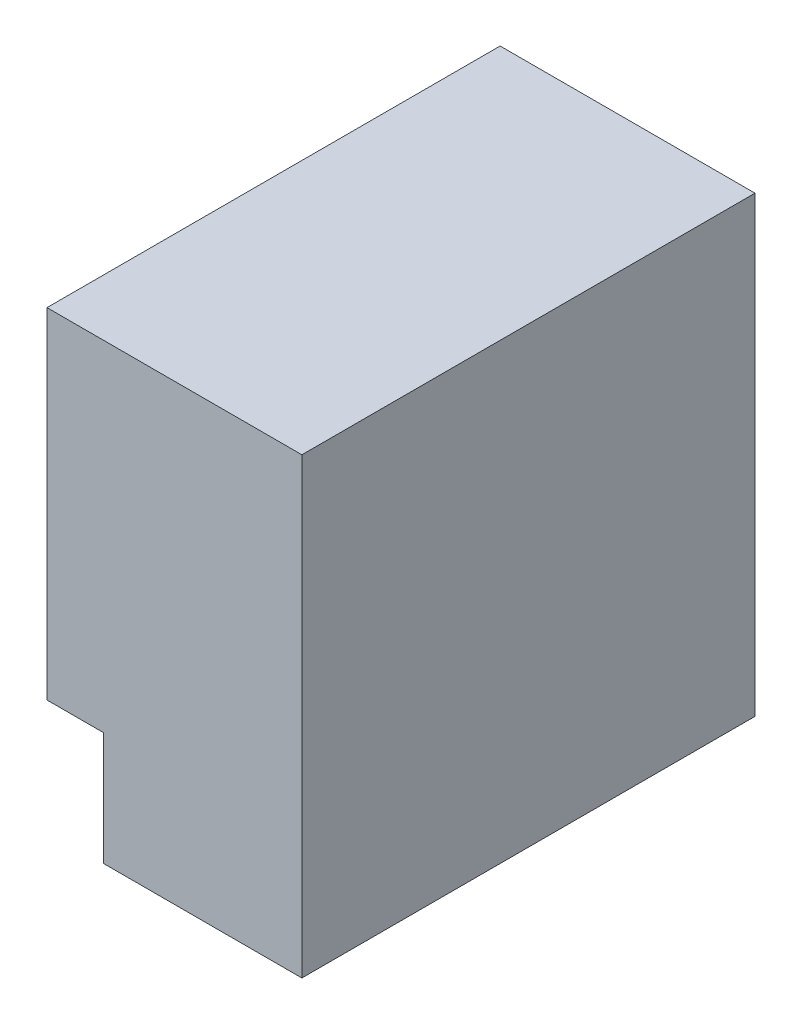
from build123d import *

# Parameters (mm, degrees)
SKETCH1_W                 = 22.5
SKETCH1_H                 = 40
BOSS_EXTRUDE1_DEPTH       = 40
SKETCH2_W                 = 5
SKETCH2_H                 = 10
CUT_EXTRUDE1_DEPTH        = 40
M3X0_5_TAPPED_HOLE2_D     = 2.5
M3X0_5_TAPPED_HOLE2_DEPTH = 6.5
M3X0_5_TAPPED_HOLE2_TIP   = 0.751075774
M3X0_5_TAPPED_HOLE3_D     = 2.5
M3X0_5_TAPPED_HOLE3_DEPTH = 6.5
M3X0_5_TAPPED_HOLE3_TIP   = 0.751075774


with BuildPart() as part:
    # Sketch1 → Boss-Extrude1 (new body)
    with BuildSketch(Plane(origin=(0, 3, 0), x_dir=(-1, 0, 0), z_dir=(0, 1, 0))):
        with Locations((5.393225555, 5.12970783)):
            Rectangle(SKETCH1_W, SKETCH1_H)
    extrude(amount=BOSS_EXTRUDE1_DEPTH)

    # Sketch2 → Cut-Extrude1 (cut)
    with BuildSketch(Plane.XY.offset(25.12970783)):
        with Locations((-14.143225555, 8)):
            Rectangle(SKETCH2_W, SKETCH2_H)
    extrude(amount=-CUT_EXTRUDE1_DEPTH, mode=Mode.SUBTRACT)

    # M3x0.5 Tapped Hole2
    with Locations(Plane.ZY.offset(16.643225555)):
        with Locations((5.12970783, 23), (5.12970783, 33)):
            Hole(M3X0_5_TAPPED_HOLE2_D / 2, depth=M3X0_5_TAPPED_HOLE2_DEPTH)
            with Locations((0, 0, -(M3X0_5_TAPPED_HOLE2_DEPTH + M3X0_5_TAPPED_HOLE2_TIP / 2))):  # 118° drill point
                Cone(0, M3X0_5_TAPPED_HOLE2_D / 2, M3X0_5_TAPPED_HOLE2_TIP, mode=Mode.SUBTRACT)

    # M3x0.5 Tapped Hole3
    with Locations(Plane.XZ.offset(-3)):
        with Locations((-2.143225555, 17.12970783), (-2.143225555, -6.87029217)):
            Hole(M3X0_5_TAPPED_HOLE3_D / 2, depth=M3X0_5_TAPPED_HOLE3_DEPTH)
            with Locations((0, 0, -(M3X0_5_TAPPED_HOLE3_DEPTH + M3X0_5_TAPPED_HOLE3_TIP / 2))):  # 118° drill point
                Cone(0, M3X0_5_TAPPED_HOLE3_D / 2, M3X0_5_TAPPED_HOLE3_TIP, mode=Mode.SUBTRACT)


solid = part.part
